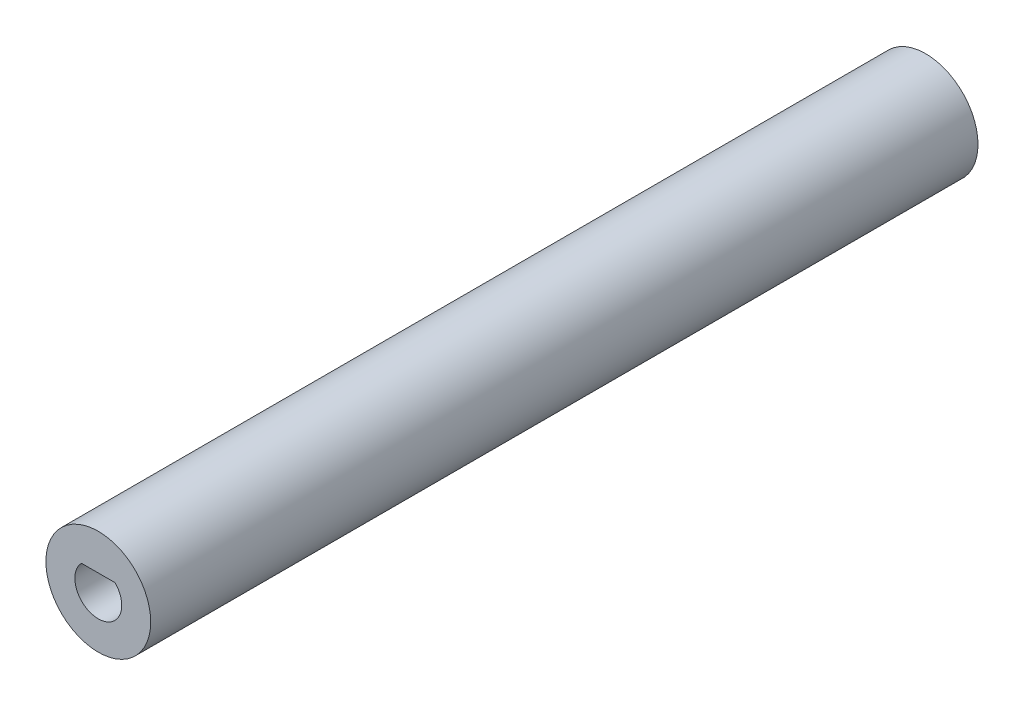
from build123d import *

# Parameters (mm, degrees)
SKETCH1_R           = 4.75
BOSS_EXTRUDE1_DEPTH = 75
CUT_EXTRUDE1_DEPTH  = 10


with BuildPart() as part:
    # Sketch1 → Boss-Extrude1 (new body)
    with BuildSketch(Plane.XY):
        Circle(SKETCH1_R)
    extrude(amount=BOSS_EXTRUDE1_DEPTH)

    # Sketch2 → Cut-Extrude1 (cut)
    with BuildSketch(Plane.XY.offset(75)):
        with BuildLine():
            Line((-1.529705854, 1.475), (1.529705854, 1.475))
            ThreePointArc((1.529705854, 1.475), (0, -2.125), (-1.529705854, 1.475))
        make_face()
    extrude(amount=-CUT_EXTRUDE1_DEPTH, mode=Mode.SUBTRACT)


solid = part.part
